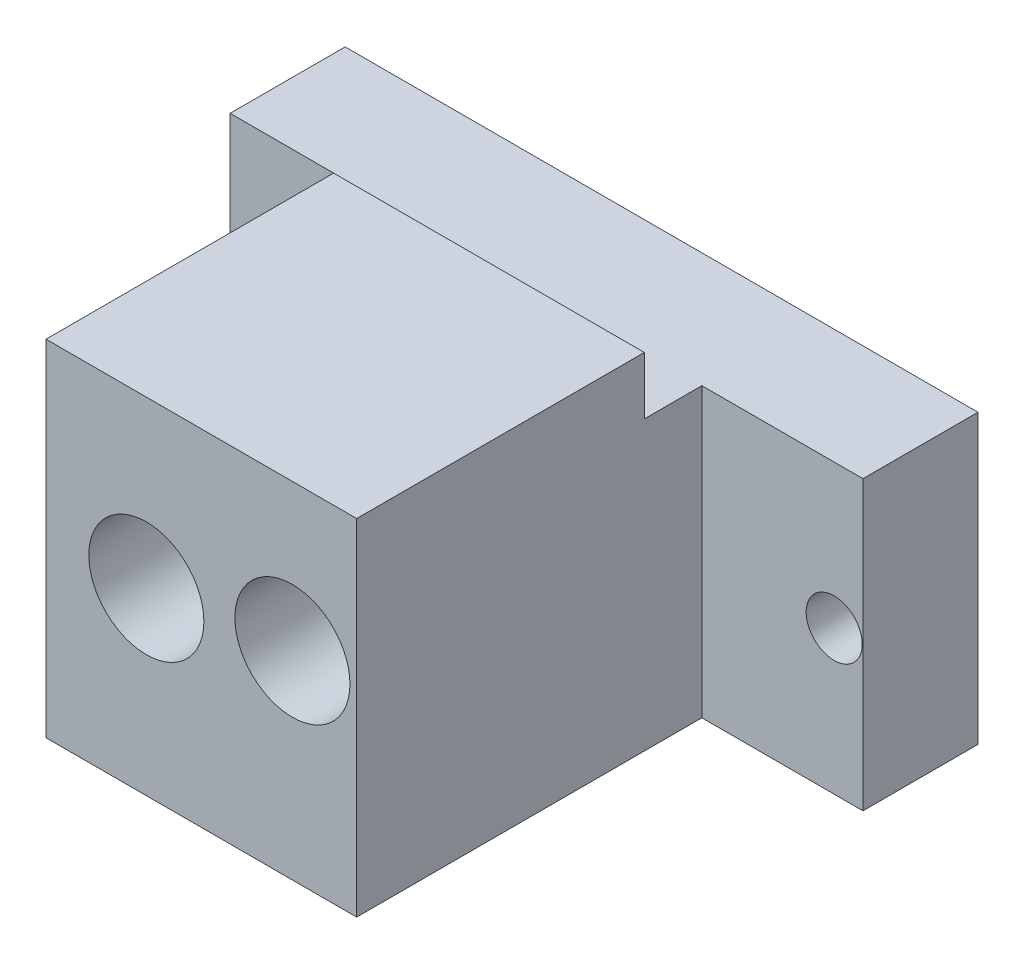
from build123d import *

# Parameters (mm, degrees)
SKETCH1_W           = 55
SKETCH1_H           = 25
SKETCH1_R           = 2.435064935
BOSS_EXTRUDE1_DEPTH = 10
SKETCH2_W           = 27
SKETCH2_H           = 25
BOSS_EXTRUDE2_DEPTH = 30
SKETCH3_W           = 27
SKETCH3_H           = 25
BOSS_EXTRUDE3_DEPTH = 30
SKETCH4_R           = 5
CUT_EXTRUDE1_DEPTH  = 20


with BuildPart() as part:
    # Sketch1 → Boss-Extrude1 (new body)
    with BuildSketch(Plane.XY):
        with Locations((27.5, 12.5)):
            Rectangle(SKETCH1_W, SKETCH1_H)
        with Locations((52.5, 12.5)):
            Circle(SKETCH1_R, mode=Mode.SUBTRACT)
        with Locations((2.5, 12.5)):
            Circle(SKETCH1_R, mode=Mode.SUBTRACT)
    extrude(amount=BOSS_EXTRUDE1_DEPTH)

    # Sketch2 → Boss-Extrude2 (add)
    with BuildSketch(Plane.XY.offset(10)):
        with Locations((27.5, 12.5)):
            Rectangle(SKETCH2_W, SKETCH2_H)
    extrude(amount=BOSS_EXTRUDE2_DEPTH)

    # Sketch3 → Boss-Extrude3 (add)
    with BuildSketch(Plane.XZ):
        with Locations((27.5, 27.5)):
            Rectangle(SKETCH3_W, SKETCH3_H)
    extrude(amount=-BOSS_EXTRUDE3_DEPTH)

    # Sketch4 → Cut-Extrude1 (cut)
    with BuildSketch(Plane.XY.offset(40)):
        with Locations((22.7215485, 15.612504219)):
            Circle(SKETCH4_R)
        with Locations((35.41615295, 17.248010158)):
            Circle(SKETCH4_R)
    extrude(amount=-CUT_EXTRUDE1_DEPTH, mode=Mode.SUBTRACT)


solid = part.part
